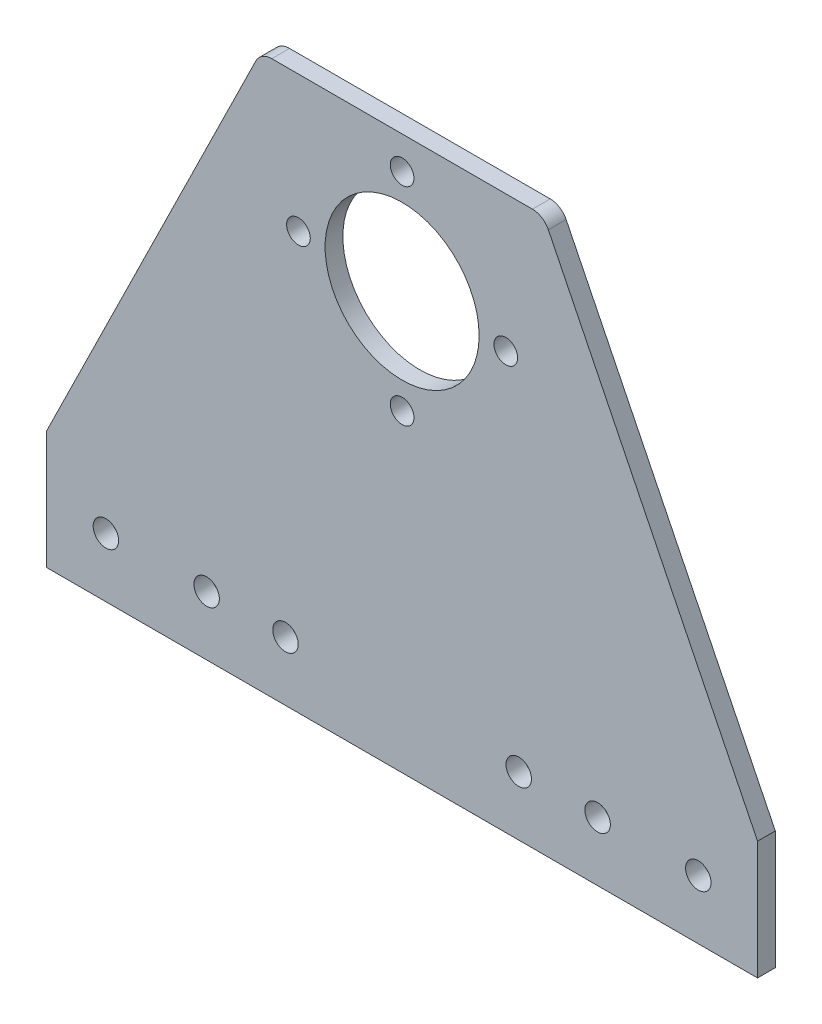
from build123d import *

# Parameters (mm, degrees)
SKETCH1_R      = 2.15
EXTRUDE1_DEPTH = 3


with BuildPart() as part:
    # Sketch1 → Extrude1 (new body)
    with BuildSketch(Plane.XY):
        with BuildLine():
            Line((46.447148798, 50.325025124), (11.138674094, -21.397126503))
            Line((11.138674094, -21.397126503), (11.138674094, -41.397126503))
            Line((11.138674094, -41.397126503), (131.138674094, -41.397126503))
            Line((131.138674094, -41.397126503), (131.138674094, -21.397126503))
            Line((131.138674094, -21.397126503), (95.830199391, 50.325025124))
            ThreePointArc((95.830199391, 50.325025124), (94.723748955, 51.547064523), (93.138674094, 52))
            Line((93.138674094, 52), (49.138674094, 52))
            ThreePointArc((49.138674094, 52), (47.553599234, 51.547064523), (46.447148798, 50.325025124))
        make_face()
        with Locations((21.138674094, -31.397126503)):
            Circle(SKETCH1_R, mode=Mode.SUBTRACT)
        with Locations((121.138674094, -31.397126503)):
            Circle(SKETCH1_R, mode=Mode.SUBTRACT)
        with Locations((104.138674094, -31.397126503)):
            Circle(SKETCH1_R, mode=Mode.SUBTRACT)
        with Locations((90.827251635, -31.397126503)):
            Circle(SKETCH1_R, mode=Mode.SUBTRACT)
        with Locations((51.450096554, -31.397126503)):
            Circle(SKETCH1_R, mode=Mode.SUBTRACT)
        with Locations((38.138674094, -31.397126503)):
            Circle(SKETCH1_R, mode=Mode.SUBTRACT)
        with BuildLine():
            ThreePointArc((69.138674094, 11.502873497), (71.138674094, 9.502873497), (73.138674094, 11.502873497))
            ThreePointArc((73.138674094, 11.502873497), (71.138674094, 13.502873497), (69.138674094, 11.502873497))
        make_face(mode=Mode.SUBTRACT)
        with BuildLine():
            ThreePointArc((51.638674094, 29.002873497), (53.638674094, 27.002873497), (55.638674094, 29.002873497))
            ThreePointArc((55.638674094, 29.002873497), (53.638674094, 31.002873497), (51.638674094, 29.002873497))
        make_face(mode=Mode.SUBTRACT)
        with BuildLine():
            ThreePointArc((69.138674094, 46.502873497), (71.138674094, 44.502873497), (73.138674094, 46.502873497))
            ThreePointArc((73.138674094, 46.502873497), (71.138674094, 48.502873497), (69.138674094, 46.502873497))
        make_face(mode=Mode.SUBTRACT)
        with BuildLine():
            ThreePointArc((86.638674094, 29.002873497), (88.638674094, 27.002873497), (90.638674094, 29.002873497))
            ThreePointArc((90.638674094, 29.002873497), (88.638674094, 31.002873497), (86.638674094, 29.002873497))
        make_face(mode=Mode.SUBTRACT)
        with BuildLine():
            ThreePointArc((58.138674094, 29.002873497), (71.138674094, 16.002873497), (84.138674094, 29.002873497))
            ThreePointArc((84.138674094, 29.002873497), (71.138674094, 42.002873497), (58.138674094, 29.002873497))
        make_face(mode=Mode.SUBTRACT)
    extrude(amount=EXTRUDE1_DEPTH)


solid = part.part
